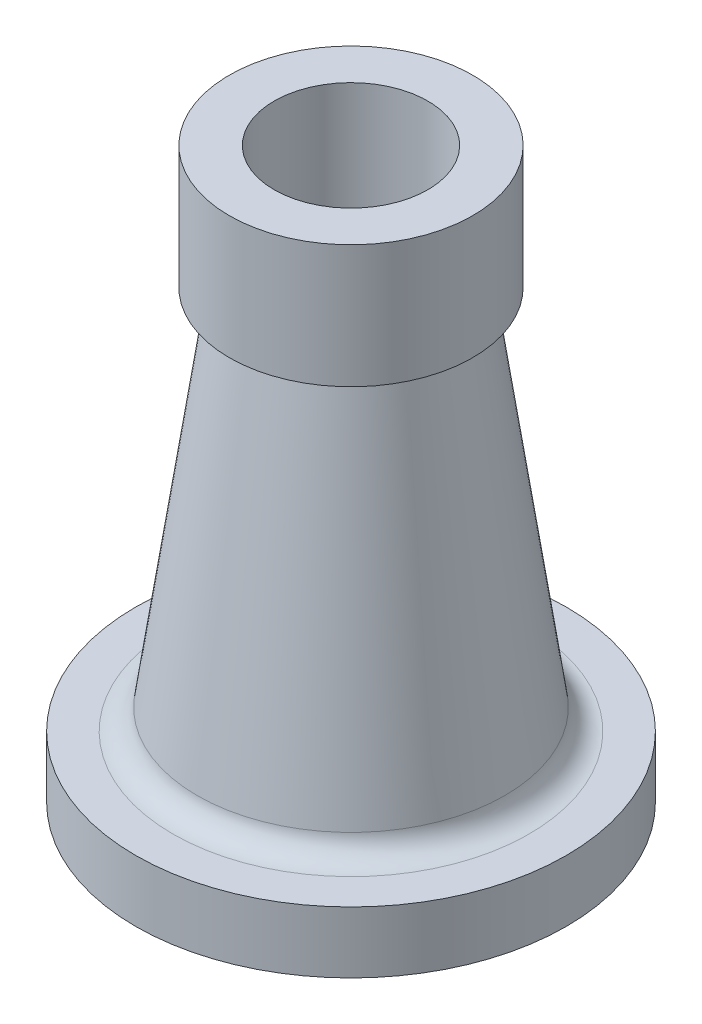
from build123d import *


with BuildPart() as part:
    # Sketch1 → Revolve1 (revolve)
    with BuildSketch(Plane.XY):
        with BuildLine():
            Line((39.587859575, 60.721319219), (39.587859575, 20.721319219))
            Line((39.587859575, 20.721319219), (34.15419798, 20.721319219))
            ThreePointArc((34.15419798, 20.721319219), (33.398410087, 20.376135729), (33.1643932, 19.578888541))
            Line((33.1643932, 19.578888541), (50, -97.418126201))
            ThreePointArc((50, -97.418126201), (52.679906162, -102.324983923), (57.918438238, -104.278680781))
            Line((57.918438238, -104.278680781), (70, -104.278680781))
            Line((70, -104.278680781), (70, -124.278680781))
            Line((70, -124.278680781), (50, -124.278680781))
            Line((50, -124.278680781), (50, -122.278680781))
            ThreePointArc((50, -122.278680781), (49.707106781, -121.571574), (49, -121.278680781))
            Line((49, -121.278680781), (43.330477707, -121.278680781))
            Line((43.330477707, -121.278680781), (35.697641886, -68.23521073))
            Line((35.697641886, -68.23521073), (25, 6.106758666))
            Line((25, 6.106758666), (25, 60.721319219))
            Line((25, 60.721319219), (39.587859575, 60.721319219))
        make_face()
    revolve(axis=Axis((0, 76.173744253, 0), (0, -1, 0)))


solid = part.part
